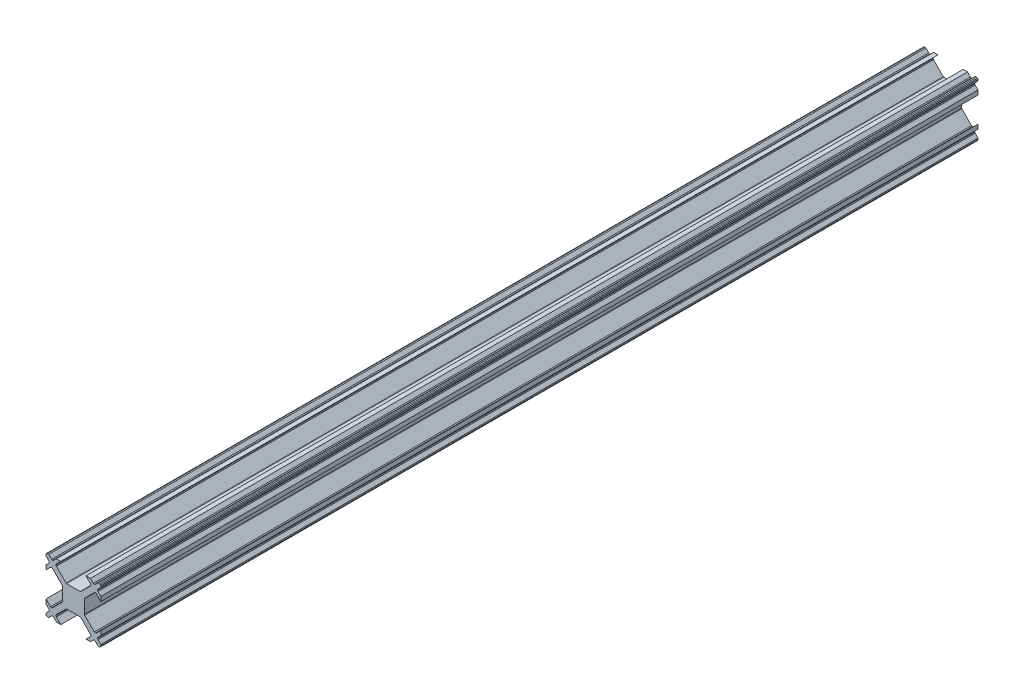
from build123d import *

# Parameters (mm, degrees)
BOSS_EXTRUDE1_DEPTH = 160


with BuildPart() as part:
    # Sketch1 → Boss-Extrude1 (new body)
    with BuildSketch(Plane.XY.offset(12.500000186)):
        Polygon((1.366116014, 2.07322405), (1.28500117, 2.01905681), (1.189340837, 2.000001485), (-1.189338975, 2.000001485), (-1.284999318, 2.019056756), (-1.366115682, 2.073224527), (-3.116116726, 3.823223591), (-3.189339968, 4.000000449), (-3.116116926, 4.176777156), (-2.292893894, 5.000000654), (-3.094975438, 5.000000654), (-3.623223835, 4.471751833), (-3.800000473, 4.398528373), (-3.976777136, 4.471751755), (-4.505025989, 5.000000654), (-4.750000613, 5.000000654), (-4.926776979, 4.926776979), (-4.999999888, 4.749999847), (-4.999999888, 4.505025223), (-4.471751419, 3.976776707), (-4.398528052, 3.800000038), (-4.471751492, 3.623223494), (-4.999999888, 3.094974672), (-4.999999888, 2.292893128), (-4.176776856, 3.116116626), (-4.00000019, 3.189339768), (-3.823223291, 3.116116626), (-2.073223237, 1.366116572), (-2.019055421, 1.285000239), (-2.000000095, 1.189339906), (-2.000000095, -1.189339906), (-2.019055549, -1.284999858), (-2.073223355, -1.366116198), (-3.823223186, -3.116116476), (-4.000000075, -3.18933964), (-4.176776751, -3.116116521), (-4.999999888, -2.292893128), (-4.999999888, -3.094974672), (-4.471751396, -3.623223398), (-4.398528021, -3.800000064), (-4.471751438, -3.976776688), (-4.999999888, -4.505025223), (-4.999999888, -4.749999847), (-4.926776979, -4.926776979), (-4.750000267, -5.000000308), (-4.505025643, -5.000000308), (-3.97677715, -4.471751815), (-3.800000484, -4.398528441), (-3.623223585, -4.471751583), (-3.094975092, -5.000000308), (-2.292893548, -5.000000308), (-3.116116686, -4.176776916), (-3.18933975, -4.000000217), (-3.116116531, -3.82322335), (-1.36611571, -2.073224063), (-1.284999353, -2.019056282), (-1.189339012, -2.000000998), (1.1893408, -2.000000998), (1.285001132, -2.019056324), (1.366116572, -2.073223237), (3.116116626, -3.823223291), (3.189339768, -4.00000019), (3.116115974, -4.176777043), (2.292892709, -5.000000308), (3.094974253, -5.000000308), (3.623222862, -4.471751699), (3.799999512, -4.398528285), (3.976776334, -4.471751792), (4.505024803, -5.000000308), (4.749999427, -5.000000308), (4.926776559, -4.926777399), (4.999999468, -4.750000267), (4.999999468, -4.505025643), (4.471750616, -3.976776744), (4.398527446, -3.800000351), (4.471750859, -3.623223701), (4.999999468, -3.094975092), (4.999999468, -2.292893548), (4.176776204, -3.116116813), (4.000004057, -3.189335443), (3.823227116, -3.116112401), (2.073226072, -1.366113337), (2.019057711, -1.285002538), (2.000002386, -1.189342206), (2.000002386, 1.189337606), (2.019057753, 1.28499793), (2.073225605, 1.36611424), (3.823226425, 3.116113528), (4.000003356, 3.189336593), (4.176775948, 3.116116484), (4.999999468, 2.292892709), (4.999999468, 3.094974253), (4.471750593, 3.623223361), (4.398527601, 3.799999644), (4.471750976, 3.97677631), (4.999999468, 4.505024803), (4.999999468, 4.749999427), (4.926776213, 4.926777745), (4.749999082, 5.000000654), (4.505024457, 5.000000654), (3.976776007, 4.471752119), (3.799999416, 4.398528093), (3.623222782, 4.471751546), (3.094973907, 5.000000654), (2.292892363, 5.000000654), (3.116115883, 4.176776879), (3.189338947, 4.00000018), (3.116115845, 3.823224328), align=None)
    extrude(amount=-BOSS_EXTRUDE1_DEPTH)


solid = part.part
